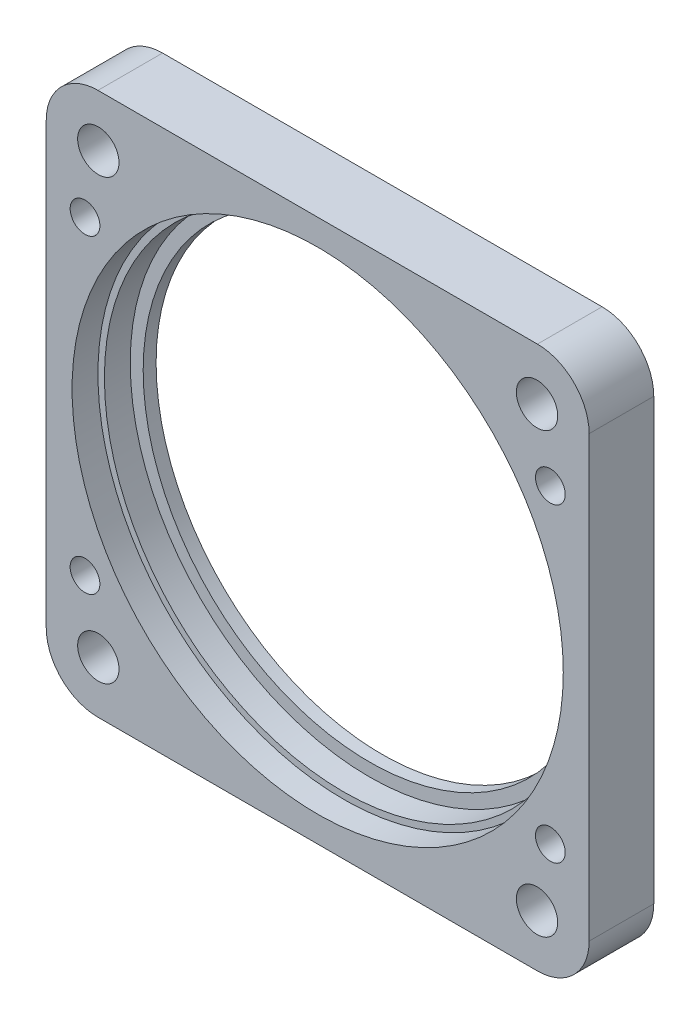
from build123d import *

# Parameters (mm, degrees)
SKETCH_1_W          = 42
SKETCH_1_H          = 42
EXTRUDE_1_DEPTH     = 5
SKETCH_2_R          = 17.5
CUT_EXTRUDE_1_DEPTH = 6
SKETCH_3_R          = 18.5
CUT_EXTRUDE_2_DEPTH = 4
SKETCH_4_R          = 19
CUT_EXTRUDE_3_DEPTH = 2
FILLET_1_R          = 4
SKETCH_5_R          = 1.6
CUT_EXTRUDE_4_DEPTH = 6
SKETCH_7_R          = 1.15
CUT_EXTRUDE_5_DEPTH = 6
SKETCH_8_R          = 2
CUT_EXTRUDE_6_DEPTH = 3


with BuildPart() as part:
    # 草图1 → 凸台-拉伸1 (new body)
    with BuildSketch(Plane.XY):
        Rectangle(SKETCH_1_W, SKETCH_1_H)
    extrude(amount=EXTRUDE_1_DEPTH)

    # 草图2 → 切除-拉伸1 (cut, through all)
    with BuildSketch(Plane.XY.offset(5)):
        Circle(SKETCH_2_R)
    extrude(amount=-CUT_EXTRUDE_1_DEPTH, mode=Mode.SUBTRACT)

    # 草图3 → 切除-拉伸2 (cut)
    with BuildSketch(Plane.XY.offset(5)):
        Circle(SKETCH_3_R)
    extrude(amount=-CUT_EXTRUDE_2_DEPTH, mode=Mode.SUBTRACT)

    # 草图4 → 切除-拉伸3 (cut)
    with BuildSketch(Plane.XY.offset(5)):
        Circle(SKETCH_4_R)
    extrude(amount=-CUT_EXTRUDE_3_DEPTH, mode=Mode.SUBTRACT)

    # 圆角1
    fillet_1_edges = [part.edges().sort_by_distance(p)[0] for p in [
        (21, -21, 2.5),
        (-21, -21, 2.5),
        (-21, 21, 2.5),
        (21, 21, 2.5),
    ]]
    fillet(fillet_1_edges, radius=FILLET_1_R)

    # 草图5 → 切除-拉伸4 (cut, through all)
    with BuildSketch(Plane.XY.offset(5)):
        with Locations((-16.970562748, 16.970562748)):
            Circle(SKETCH_5_R)
        with Locations((16.970562748, 16.970562748)):
            Circle(SKETCH_5_R)
        with Locations((16.970562748, -16.970562748)):
            Circle(SKETCH_5_R)
        with Locations((-16.970562748, -16.970562748)):
            Circle(SKETCH_5_R)
    extrude(amount=-CUT_EXTRUDE_4_DEPTH, mode=Mode.SUBTRACT)

    # 草图7 → 切除-拉伸5 (cut, through all)
    with BuildSketch(Plane(origin=(0, 0, 0), x_dir=(-1, 0, 0), z_dir=(0, 0, -1))):
        with Locations((-18, 12)):
            Circle(SKETCH_7_R)
        with Locations((18, 12)):
            Circle(SKETCH_7_R)
        with Locations((18, -12)):
            Circle(SKETCH_7_R)
        with Locations((-18, -12)):
            Circle(SKETCH_7_R)
    extrude(amount=-CUT_EXTRUDE_5_DEPTH, mode=Mode.SUBTRACT)

    # 草图8 → 切除-拉伸6 (cut)
    with BuildSketch(Plane(origin=(0, 0, 0), x_dir=(-1, 0, 0), z_dir=(0, 0, -1))):
        with Locations((-18, 12)):
            Circle(SKETCH_8_R)
        with Locations((18, 12)):
            Circle(SKETCH_8_R)
        with Locations((18, -12)):
            Circle(SKETCH_8_R)
        with Locations((-18, -12)):
            Circle(SKETCH_8_R)
    extrude(amount=-CUT_EXTRUDE_6_DEPTH, mode=Mode.SUBTRACT)


solid = part.part
